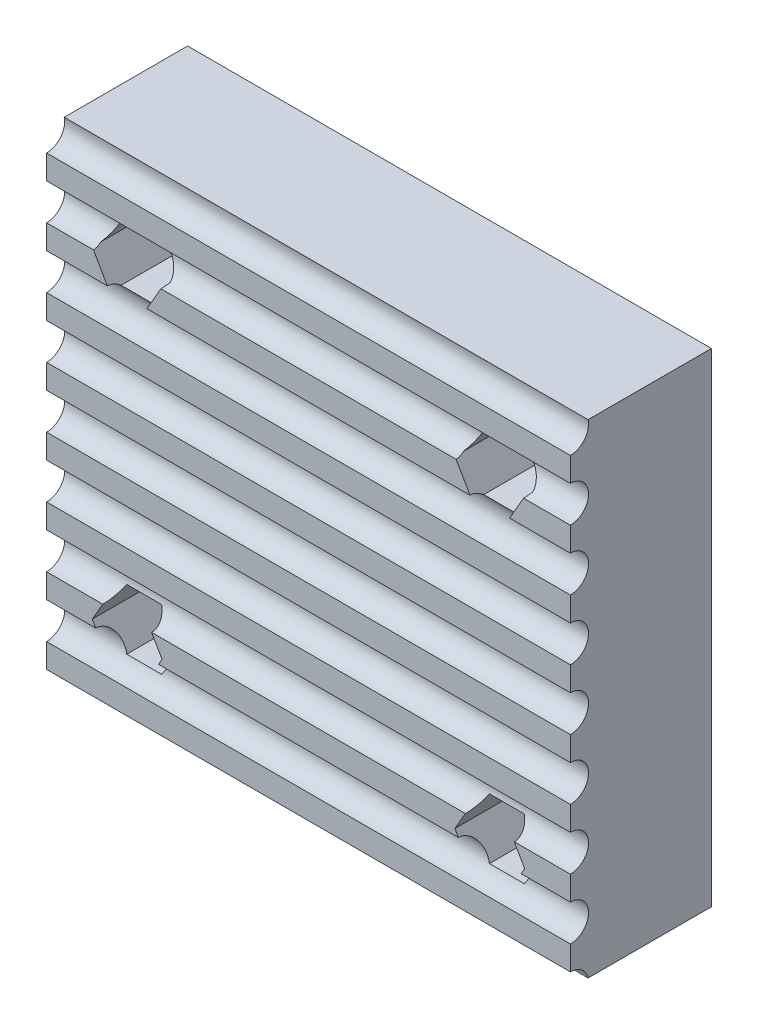
from build123d import *

# Parameters (mm, degrees)
SKETCH3_W           = 26
SKETCH3_H           = 24
BOSS_EXTRUDE2_DEPTH = 7
SKETCH7_R           = 0.9
CUT_EXTRUDE1_DEPTH  = 27


with BuildPart() as part:
    # Sketch3 → Boss-Extrude2 (new body)
    with BuildSketch(Plane.XY):
        with Locations((13, 12)):
            Rectangle(SKETCH3_W, SKETCH3_H)
        Polygon((5.732050808, 4), (4.866025404, 5.5), (3.133974596, 5.5), (2.267949192, 4), (3.133974596, 2.5), (4.866025404, 2.5), align=None, mode=Mode.SUBTRACT)
        Polygon((5.732050808, 20), (4.866025404, 21.5), (3.133974596, 21.5), (2.267949192, 20), (3.133974596, 18.5), (4.866025404, 18.5), align=None, mode=Mode.SUBTRACT)
        Polygon((23.732050808, 20), (22.866025404, 21.5), (21.133974596, 21.5), (20.267949192, 20), (21.133974596, 18.5), (22.866025404, 18.5), align=None, mode=Mode.SUBTRACT)
        Polygon((23.732050808, 4), (22.866025404, 5.5), (21.133974596, 5.5), (20.267949192, 4), (21.133974596, 2.5), (22.866025404, 2.5), align=None, mode=Mode.SUBTRACT)
    extrude(amount=BOSS_EXTRUDE2_DEPTH)

    # Sketch7 → Cut-Extrude1 (cut, through all)
    with BuildSketch(Plane(origin=(26, 0, 0), x_dir=(0, 0, -1), z_dir=(1, 0, 0))):
        with Locations((-7, 23.8)):
            Circle(SKETCH7_R)
        with Locations((-7, 20.8)):
            Circle(SKETCH7_R)
        with Locations((-7, 17.8)):
            Circle(SKETCH7_R)
        with Locations((-7, 14.8)):
            Circle(SKETCH7_R)
        with Locations((-7, 11.8)):
            Circle(SKETCH7_R)
        with Locations((-7, 8.8)):
            Circle(SKETCH7_R)
        with Locations((-7, 5.8)):
            Circle(SKETCH7_R)
        with Locations((-7, 2.8)):
            Circle(SKETCH7_R)
        with Locations((-7, -0.2)):
            Circle(SKETCH7_R)
    extrude(amount=-CUT_EXTRUDE1_DEPTH, mode=Mode.SUBTRACT)


solid = part.part
